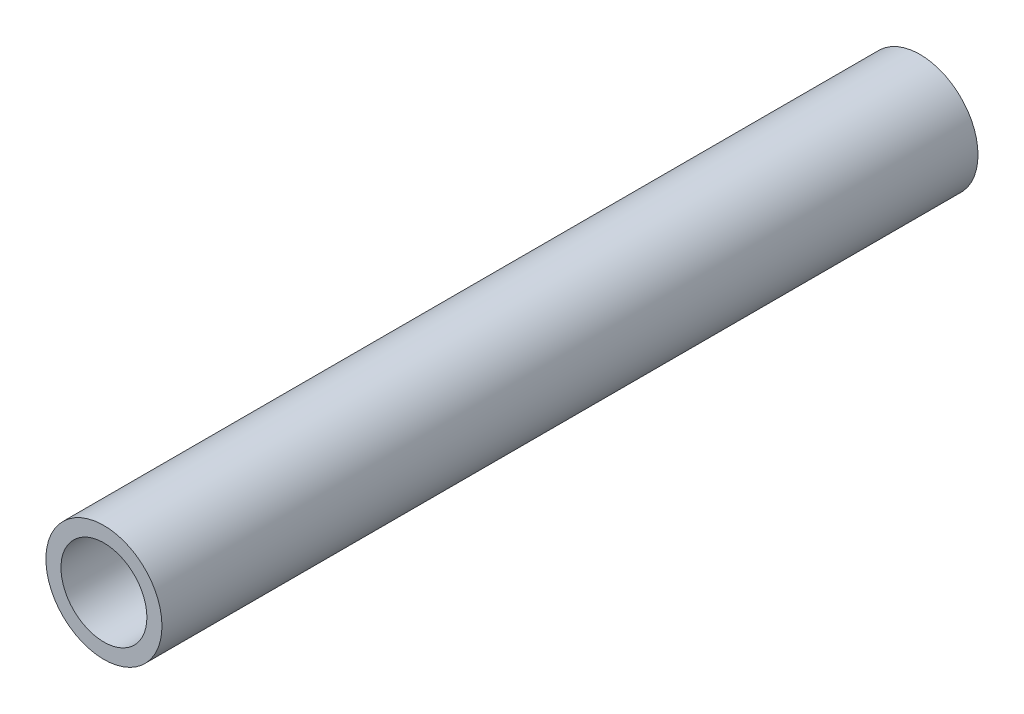
from build123d import *

# Parameters (mm, degrees)
SKETCH1_R           = 10.668
SKETCH1_R_2         = 7.8994
EXTRUDE_THIN1_DEPTH = 75


with BuildPart() as part:
    # Sketch1 → Extrude-Thin1 (new body, symmetric)
    with BuildSketch(Plane.XY):
        Circle(SKETCH1_R)
        Circle(SKETCH1_R_2, mode=Mode.SUBTRACT)
    extrude(amount=EXTRUDE_THIN1_DEPTH, both=True)


solid = part.part
